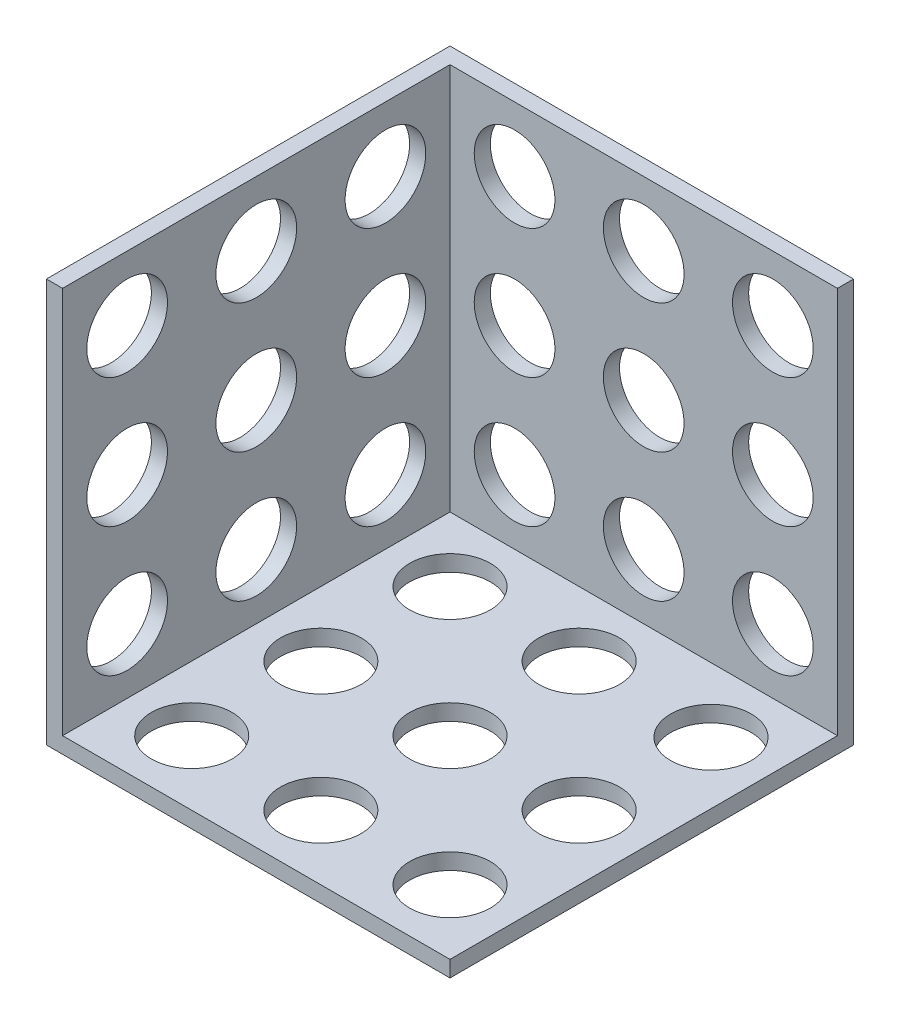
from build123d import *

# Parameters (mm, degrees)
SKETCH1_W           = 80
SKETCH1_H           = 80
SKETCH1_R           = 25
BOSS_EXTRUDE1_DEPTH = 10
SKETCH3_W           = 80
SKETCH3_H           = 80
SKETCH3_R           = 25
BOSS_EXTRUDE2_DEPTH = 10
SKETCH4_R           = 25
SKETCH4_W           = 80
SKETCH4_H           = 80
BOSS_EXTRUDE3_DEPTH = 10


with BuildPart() as part:
    # Sketch1 → Boss-Extrude1 (new body)
    with BuildSketch(Plane(origin=(0, 0, 0), x_dir=(1, 0, 0), z_dir=(0, 1, 0))):
        with Locations((40, -40)):
            Rectangle(SKETCH1_W, SKETCH1_H)
        with Locations((40, -40)):
            Circle(SKETCH1_R, mode=Mode.SUBTRACT)
        with Locations((120, -40)):
            Rectangle(SKETCH1_W, SKETCH1_H)
        with Locations((120, -40)):
            Circle(SKETCH1_R, mode=Mode.SUBTRACT)
        with Locations((200, -40)):
            Rectangle(SKETCH1_W, SKETCH1_H)
        with Locations((200, -40)):
            Circle(SKETCH1_R, mode=Mode.SUBTRACT)
        with Locations((200, 40)):
            Rectangle(SKETCH1_W, SKETCH1_H)
        with Locations((200, 40)):
            Circle(SKETCH1_R, mode=Mode.SUBTRACT)
        with Locations((120, 40)):
            Rectangle(SKETCH1_W, SKETCH1_H)
        with Locations((120, 40)):
            Circle(SKETCH1_R, mode=Mode.SUBTRACT)
        with Locations((40, 40)):
            Rectangle(SKETCH1_W, SKETCH1_H)
        with Locations((40, 40)):
            Circle(SKETCH1_R, mode=Mode.SUBTRACT)
        with Locations((40, 120)):
            Rectangle(SKETCH1_W, SKETCH1_H)
        with Locations((40, 120)):
            Circle(SKETCH1_R, mode=Mode.SUBTRACT)
        with Locations((120, 120)):
            Rectangle(SKETCH1_W, SKETCH1_H)
        with Locations((120, 120)):
            Circle(SKETCH1_R, mode=Mode.SUBTRACT)
        with Locations((200, 120)):
            Rectangle(SKETCH1_W, SKETCH1_H)
        with Locations((201.671071705, 120)):
            Circle(SKETCH1_R, mode=Mode.SUBTRACT)
    extrude(amount=BOSS_EXTRUDE1_DEPTH)

    # Sketch3 → Boss-Extrude2 (add)
    with BuildSketch(Plane(origin=(0, 0, -160), x_dir=(-1, 0, 0), z_dir=(0, 0, -1))):
        with Locations((-200, 130)):
            Rectangle(SKETCH3_W, SKETCH3_H)
        with Locations((-200, 130)):
            Circle(SKETCH3_R, mode=Mode.SUBTRACT)
        Polygon((-213.333333333, 90), (-240, 90), (-240, 63.333333333), (-240, 36.666666667), (-240, 10), (-213.333333333, 10), (-186.666666667, 10), (-160, 10), (-160, 36.666666667), (-160, 63.333333333), (-160, 90), (-186.666666667, 90), align=None)
        with Locations((-200, 50)):
            Circle(SKETCH3_R, mode=Mode.SUBTRACT)
        Polygon((-213.333333333, 10), (-240, 10), (-240, 0), (0, 0), (0, 10), (-26.666666667, 10), (-53.333333333, 10), (-80, 10), (-106.666666667, 10), (-133.333333333, 10), (-160, 10), (-186.666666667, 10), align=None)
        Polygon((-133.333333333, 90), (-160, 90), (-160, 63.333333333), (-160, 36.666666667), (-160, 10), (-133.333333333, 10), (-106.666666667, 10), (-80, 10), (-80, 36.666666667), (-80, 63.333333333), (-80, 90), (-106.666666667, 90), align=None)
        with Locations((-120, 50)):
            Circle(SKETCH3_R, mode=Mode.SUBTRACT)
        Polygon((-53.333333333, 90), (-80, 90), (-80, 63.333333333), (-80, 36.666666667), (-80, 10), (-53.333333333, 10), (-26.666666667, 10), (0, 10), (0, 36.666666667), (0, 63.333333333), (0, 90), (-26.666666667, 90), align=None)
        with Locations((-40, 50)):
            Circle(SKETCH3_R, mode=Mode.SUBTRACT)
        with Locations((-40, 130)):
            Rectangle(SKETCH3_W, SKETCH3_H)
        with Locations((-40, 130)):
            Circle(SKETCH3_R, mode=Mode.SUBTRACT)
        with Locations((-120, 130)):
            Rectangle(SKETCH3_W, SKETCH3_H)
        with Locations((-120, 130)):
            Circle(SKETCH3_R, mode=Mode.SUBTRACT)
        with Locations((-120, 210)):
            Rectangle(SKETCH3_W, SKETCH3_H)
        with Locations((-120, 210)):
            Circle(SKETCH3_R, mode=Mode.SUBTRACT)
        with Locations((-40, 210)):
            Rectangle(SKETCH3_W, SKETCH3_H)
        with Locations((-40, 210)):
            Circle(SKETCH3_R, mode=Mode.SUBTRACT)
        with Locations((-200, 210)):
            Rectangle(SKETCH3_W, SKETCH3_H)
        with Locations((-200, 210)):
            Circle(SKETCH3_R, mode=Mode.SUBTRACT)
    extrude(amount=BOSS_EXTRUDE2_DEPTH)

    # Sketch4 → Boss-Extrude3 (add)
    with BuildSketch(Plane.ZY):
        Polygon((-133.333333333, 90), (-160, 90), (-160, 63.333333333), (-160, 36.666666667), (-160, 10), (-133.333333333, 10), (-106.666666667, 10), (-80, 10), (-80, 36.666666667), (-80, 63.333333333), (-80, 90), (-106.666666667, 90), align=None)
        with Locations((-120, 50)):
            Circle(SKETCH4_R, mode=Mode.SUBTRACT)
        Polygon((-133.333333333, 170), (-160, 170), (-160, 143.333333333), (-160, 116.666666667), (-160, 90), (-133.333333333, 90), (-106.666666667, 90), (-80, 90), (-80, 116.666666667), (-80, 143.333333333), (-80, 170), (-106.666666667, 170), align=None)
        with Locations((-120, 130)):
            Circle(SKETCH4_R, mode=Mode.SUBTRACT)
        Polygon((-160, 196.666666667), (-160, 170), (-133.333333333, 170), (-106.666666667, 170), (-80, 170), (-80, 196.666666667), (-80, 223.333333333), (-80, 250), (-106.666666667, 250), (-133.333333333, 250), (-160, 250), (-160, 223.333333333), align=None)
        with Locations((-120, 210)):
            Circle(SKETCH4_R, mode=Mode.SUBTRACT)
        with Locations((-40, 210)):
            Rectangle(SKETCH4_W, SKETCH4_H)
        with Locations((-40, 210)):
            Circle(SKETCH4_R, mode=Mode.SUBTRACT)
        with Locations((-40, 130)):
            Rectangle(SKETCH4_W, SKETCH4_H)
        with Locations((-40, 130)):
            Circle(SKETCH4_R, mode=Mode.SUBTRACT)
        Polygon((-53.333333333, 90), (-80, 90), (-80, 63.333333333), (-80, 36.666666667), (-80, 10), (-53.333333333, 10), (-26.666666667, 10), (0, 10), (0, 36.666666667), (0, 63.333333333), (0, 90), (-26.666666667, 90), align=None)
        with Locations((-40, 50)):
            Circle(SKETCH4_R, mode=Mode.SUBTRACT)
        Polygon((53.333333333, 10), (80, 10), (80, 36.666666667), (80, 63.333333333), (80, 90), (53.333333333, 90), (26.666666667, 90), (0, 90), (0, 63.333333333), (0, 36.666666667), (0, 10), (26.666666667, 10), align=None)
        with Locations((40, 50)):
            Circle(SKETCH4_R, mode=Mode.SUBTRACT)
        with Locations((40, 130)):
            Rectangle(SKETCH4_W, SKETCH4_H)
        with Locations((40, 130)):
            Circle(SKETCH4_R, mode=Mode.SUBTRACT)
        with Locations((40, 210)):
            Rectangle(SKETCH4_W, SKETCH4_H)
        with Locations((40, 210)):
            Circle(SKETCH4_R, mode=Mode.SUBTRACT)
        Polygon((-160, 143.333333333), (-160, 170), (-160, 196.666666667), (-160, 223.333333333), (-160, 250), (-170, 250), (-170, 0), (80, 0), (80, 10), (53.333333333, 10), (26.666666667, 10), (0, 10), (-26.666666667, 10), (-53.333333333, 10), (-80, 10), (-106.666666667, 10), (-133.333333333, 10), (-160, 10), (-160, 36.666666667), (-160, 63.333333333), (-160, 90), (-160, 116.666666667), align=None)
    extrude(amount=BOSS_EXTRUDE3_DEPTH)


solid = part.part
